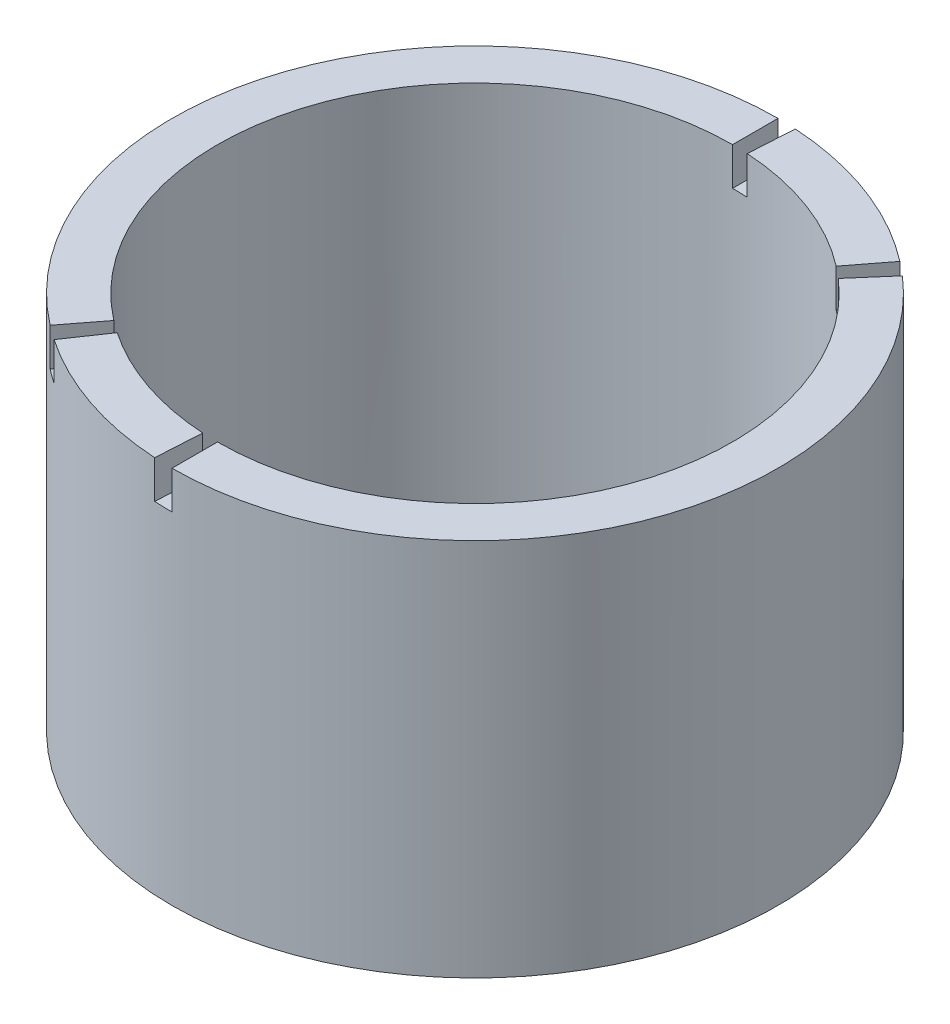
from build123d import *

# Parameters (mm, degrees)
ESQUISSE1_R      = 40
ESQUISSE1_R_2    = 34
EXTRUSION1_DEPTH = 50
EXTRUSION2_DEPTH = 5


with BuildPart() as part:
    # Esquisse1 → Extrusion1 (new body)
    with BuildSketch(Plane(origin=(0, 0, 0), x_dir=(1, 0, 0), z_dir=(0, 1, 0))):
        Circle(ESQUISSE1_R)
        Circle(ESQUISSE1_R_2, mode=Mode.SUBTRACT)
    extrude(amount=EXTRUSION1_DEPTH)

    # Esquisse2 → Extrusion2 (cut)
    with BuildSketch(Plane(origin=(0, 50, 0), x_dir=(1, 0, 0), z_dir=(0, 1, 0))):
        with BuildLine():
            Line((0, -40), (0, -34))
            ThreePointArc((0, -34), (-1.000433182, -33.985278187), (-2, -33.941125497))
            Line((-2, -33.941125497), (-2.352941176, -39.930735879))
            ThreePointArc((-2.352941176, -39.930735879), (-1.176980214, -39.98268022), (0, -40))
        make_face()
        with BuildLine():
            Line((0, 40), (0, 34))
            ThreePointArc((0, 34), (1.000433182, 33.985278187), (2, 33.941125497))
            Line((2, 33.941125497), (2.352941176, 39.930735879))
            ThreePointArc((2.352941176, 39.930735879), (1.176980214, 39.98268022), (0, 40))
        make_face()
        with BuildLine():
            Line((24.395604074, 31.699440088), (20.736263463, 26.944524075))
            ThreePointArc((20.736263463, 26.944524075), (21.519778552, 26.322977245), (22.284673889, 25.678654748))
            Line((22.284673889, 25.678654748), (26.217263399, 30.210182057))
            ThreePointArc((26.217263399, 30.210182057), (25.317386532, 30.968208524), (24.395604074, 31.699440088))
        make_face()
        with BuildLine():
            Line((-22.489530894, -33.079011475), (-19.11610126, -28.117159754))
            ThreePointArc((-19.11610126, -28.117159754), (-19.934806548, -27.542757449), (-20.736263463, -26.944524075))
            Line((-20.736263463, -26.944524075), (-24.395604074, -31.699440088))
            ThreePointArc((-24.395604074, -31.699440088), (-23.452713586, -32.403244058), (-22.489530894, -33.079011475))
        make_face()
    extrude(amount=-EXTRUSION2_DEPTH, mode=Mode.SUBTRACT)


solid = part.part
